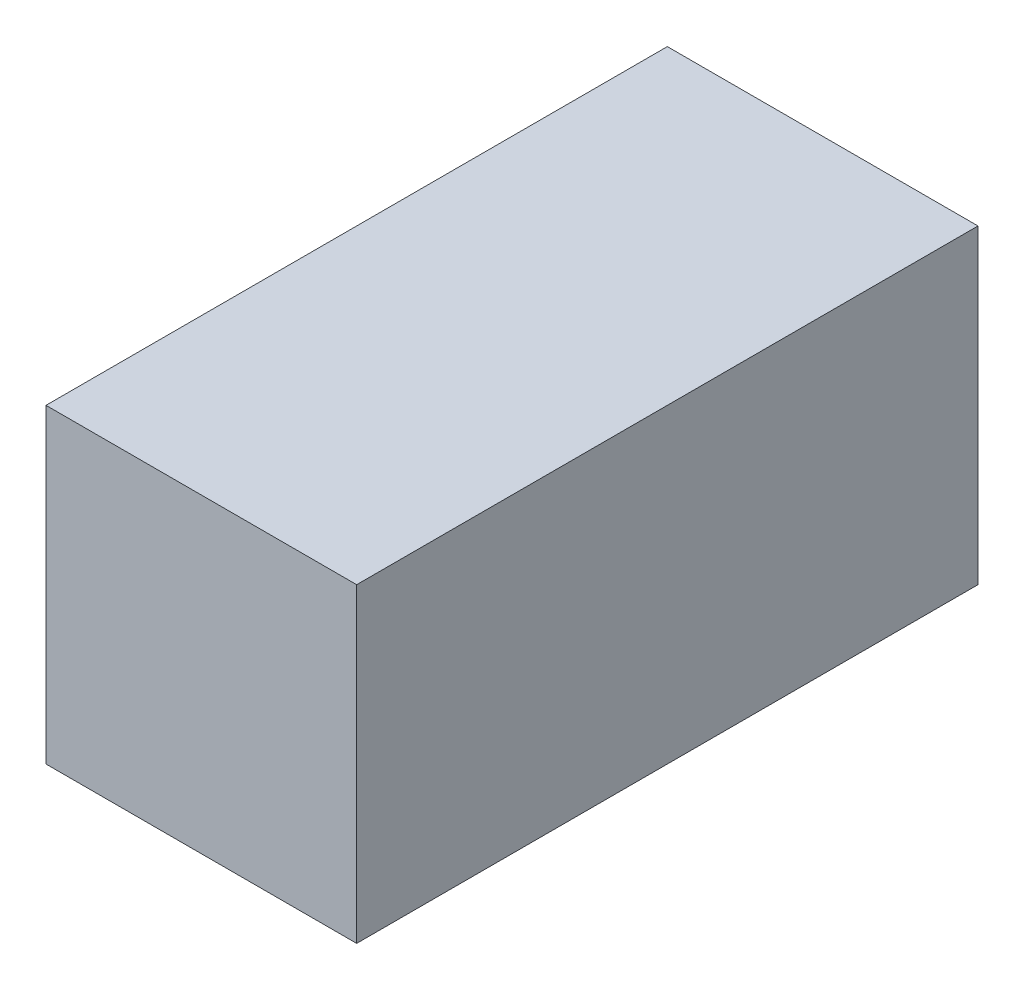
from build123d import *

# Parameters (mm, degrees)
SKETCH1_W           = 12
SKETCH1_H           = 24
BOSS_EXTRUDE1_DEPTH = 12


with BuildPart() as part:
    # Sketch1 → Boss-Extrude1 (new body)
    with BuildSketch(Plane(origin=(0, 0, 0), x_dir=(1, 0, 0), z_dir=(0, 1, 0))):
        Rectangle(SKETCH1_W, SKETCH1_H)
    extrude(amount=BOSS_EXTRUDE1_DEPTH)


solid = part.part
